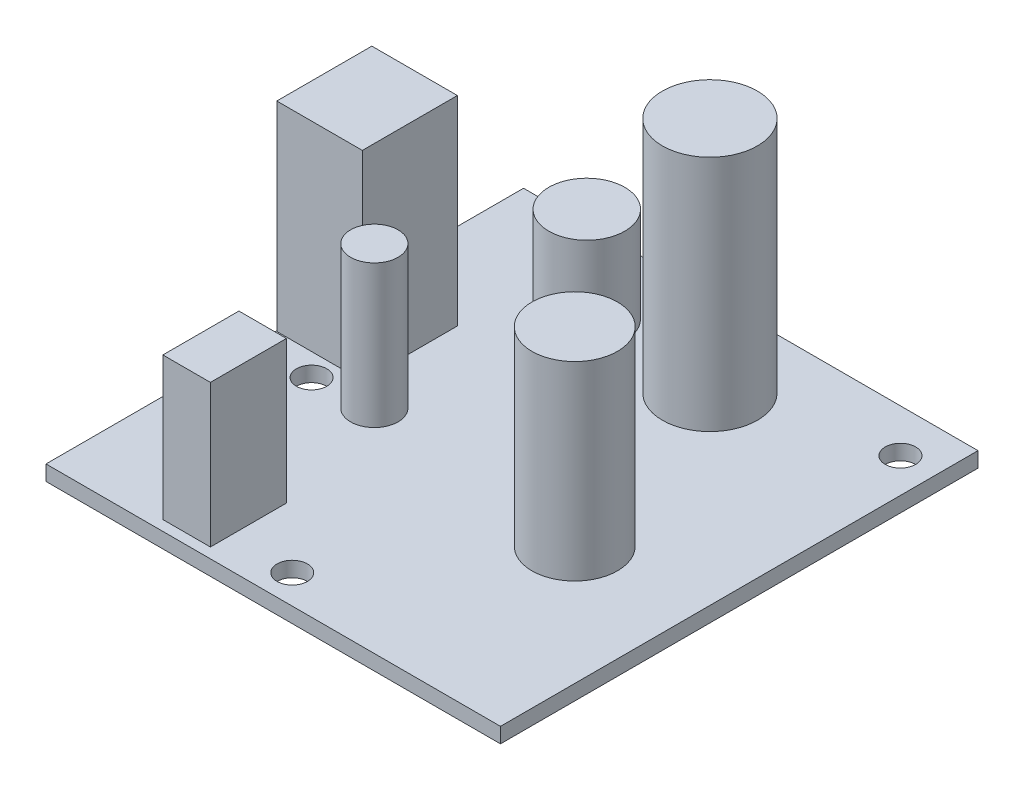
from build123d import *

# Parameters (mm, degrees)
SKETCH1_R           = 5
BOSS_EXTRUDE3_DEPTH = 25
SKETCH1_7_W         = 9
SKETCH1_7_H         = 10
BOSS_EXTRUDE4_DEPTH = 21
SKETCH1_8_R         = 4.5
BOSS_EXTRUDE5_DEPTH = 20
SKETCH1_9_W         = 5
SKETCH1_9_H         = 8
BOSS_EXTRUDE6_DEPTH = 15
SKETCH1_10_R        = 2.5
BOSS_EXTRUDE7_DEPTH = 15
SKETCH1_11_W        = 47.81426875
SKETCH1_11_H        = 50.24035
SKETCH1_11_R        = 5
SKETCH1_11_R_2      = 4.5
SKETCH1_11_R_3      = 2.5
SKETCH1_11_R_4      = 4
SKETCH1_11_R_5      = 1.6
SKETCH1_11_W_2      = 9
SKETCH1_11_H_2      = 10
SKETCH1_11_W_3      = 5
SKETCH1_11_H_3      = 8
BOSS_EXTRUDE8_DEPTH = 1.6
SKETCH1_12_R        = 4
BOSS_EXTRUDE9_DEPTH = 10


with BuildPart() as part:
    # Sketch1 → Boss-Extrude3 (new body)
    with BuildSketch(Plane(origin=(0, 0, 0), x_dir=(1, 0, 0), z_dir=(0, 1, 0))):
        with Locations((28.448, 41.402)):
            Circle(SKETCH1_R)
    extrude(amount=BOSS_EXTRUDE3_DEPTH)


with BuildPart() as body_2:
    # Sketch1_7 → Boss-Extrude4 (new body)
    with BuildSketch(Plane(origin=(0, 0, 0), x_dir=(1, 0, 0), z_dir=(0, 1, 0))):
        with Locations((4.572, 29.21)):
            Rectangle(SKETCH1_7_W, SKETCH1_7_H)
    extrude(amount=BOSS_EXTRUDE4_DEPTH)


with BuildPart() as body_3:
    # Sketch1_8 → Boss-Extrude5 (new body)
    with BuildSketch(Plane(origin=(0, 0, 0), x_dir=(1, 0, 0), z_dir=(0, 1, 0))):
        with Locations((35.306, 20.32)):
            Circle(SKETCH1_8_R)
    extrude(amount=BOSS_EXTRUDE5_DEPTH)


with BuildPart() as body_4:
    # Sketch1_9 → Boss-Extrude6 (new body)
    with BuildSketch(Plane(origin=(0, 0, 0), x_dir=(1, 0, 0), z_dir=(0, 1, 0))):
        with Locations((13.716, 5.08)):
            Rectangle(SKETCH1_9_W, SKETCH1_9_H)
    extrude(amount=BOSS_EXTRUDE6_DEPTH)


with BuildPart() as body_5:
    # Sketch1_10 → Boss-Extrude7 (new body)
    with BuildSketch(Plane(origin=(0, 0, 0), x_dir=(1, 0, 0), z_dir=(0, 1, 0))):
        with Locations((12.192, 22.352)):
            Circle(SKETCH1_10_R)
    extrude(amount=BOSS_EXTRUDE7_DEPTH)


with BuildPart() as body_6:
    # Sketch1_11 → Boss-Extrude8 (new body)
    with BuildSketch(Plane(origin=(0, 0, 0), x_dir=(1, 0, 0), z_dir=(0, 1, 0))):
        with Locations((23.907134375, 25.120175)):
            Rectangle(SKETCH1_11_W, SKETCH1_11_H)
        with Locations((28.448, 41.402)):
            Circle(SKETCH1_11_R, mode=Mode.SUBTRACT)
        with Locations((35.306, 20.32)):
            Circle(SKETCH1_11_R_2, mode=Mode.SUBTRACT)
        with Locations((12.192, 22.352)):
            Circle(SKETCH1_11_R_3, mode=Mode.SUBTRACT)
        with Locations((15.24, 41.656)):
            Circle(SKETCH1_11_R_4, mode=Mode.SUBTRACT)
        with Locations((6.096, 21.844)):
            Circle(SKETCH1_11_R_5, mode=Mode.SUBTRACT)
        with Locations((44.196, 45.7)):
            Circle(SKETCH1_11_R_5, mode=Mode.SUBTRACT)
        with Locations((22.86, 3.048)):
            Circle(SKETCH1_11_R_5, mode=Mode.SUBTRACT)
        with Locations((4.572, 29.21)):
            Rectangle(SKETCH1_11_W_2, SKETCH1_11_H_2, mode=Mode.SUBTRACT)
        with Locations((13.716, 5.08)):
            Rectangle(SKETCH1_11_W_3, SKETCH1_11_H_3, mode=Mode.SUBTRACT)
    extrude(amount=-BOSS_EXTRUDE8_DEPTH)


with BuildPart() as body_7:
    # Sketch1_12 → Boss-Extrude9 (new body)
    with BuildSketch(Plane(origin=(0, 0, 0), x_dir=(1, 0, 0), z_dir=(0, 1, 0))):
        with Locations((15.24, 41.656)):
            Circle(SKETCH1_12_R)
    extrude(amount=BOSS_EXTRUDE9_DEPTH)


solid = Compound([part.part, body_2.part, body_3.part, body_4.part, body_5.part, body_6.part, body_7.part])
